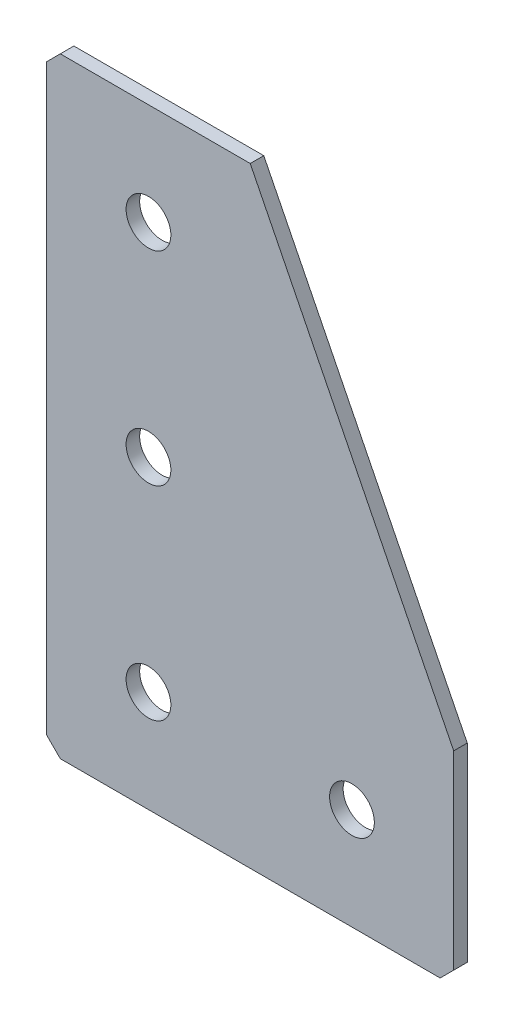
from build123d import *

# Parameters (mm, degrees)
EXTRUDE_1_DEPTH   = 2
HOLE_WIZARD_M61_D = 6.6
CHAMFER_1_SIZE    = 2


with BuildPart() as part:
    # Эскиз1 → Бобышка-Вытянуть1 (new body)
    with BuildSketch(Plane(origin=(0, 0, 0), x_dir=(1, 0, 0), z_dir=(0, 0, -1))):
        Polygon((0, 0), (0, 90), (60, 90), (60, 60), (30, 0), align=None)
    extrude(amount=EXTRUDE_1_DEPTH)

    # Отверстие с зазором M61 (through all)
    with Locations(Plane(origin=(0, 0, -2), x_dir=(1, 0, 0), z_dir=(0, 0, -1))):
        with Locations((45, 75), (15, 75), (15, 45), (15, 15)):
            Hole(HOLE_WIZARD_M61_D / 2)

    # Фаска1
    chamfer_1_edges = [part.edges().sort_by_distance(p)[0] for p in [
        (0, 0, -1),
        (0, -90, -1),
        (60, -90, -1),
    ]]
    chamfer(chamfer_1_edges, length=CHAMFER_1_SIZE)


solid = part.part
